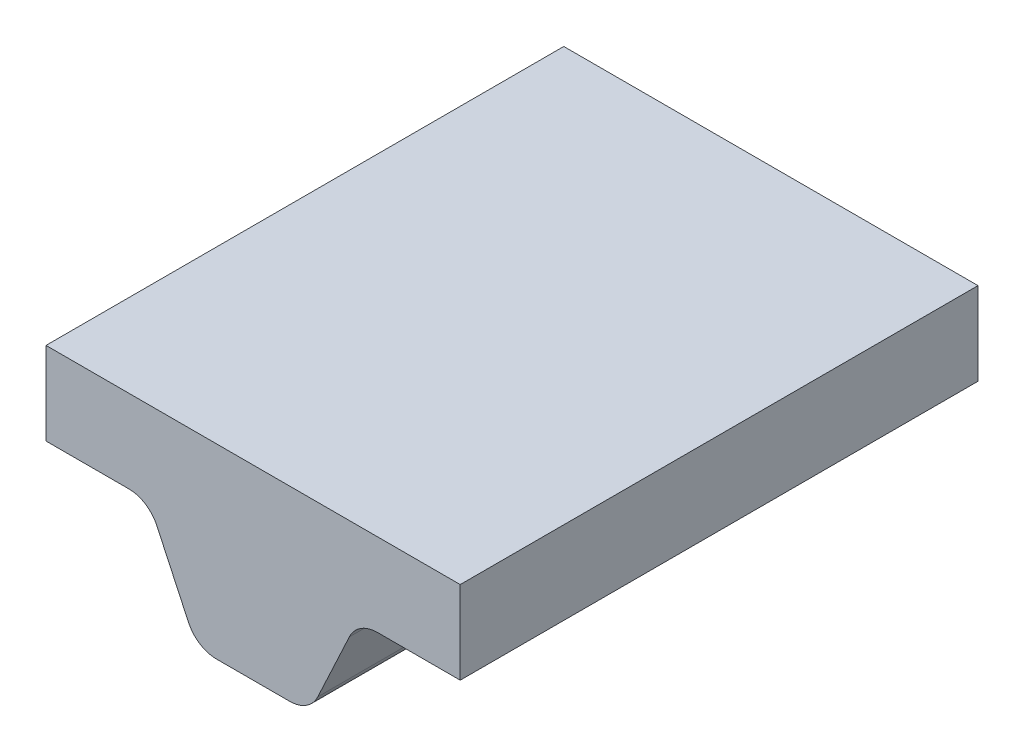
from build123d import *

# Parameters (mm, degrees)
BOSS_EXTRUDE1_DEPTH = 3.175


with BuildPart() as part:
    # Sketch1 → Boss-Extrude1 (new, symmetric)
    with BuildSketch(Plane.XY):
        with BuildLine():
            Line((2.54, -0.508), (2.54, 0.508))
            Line((2.54, 0.508), (-2.54, 0.508))
            Line((-2.54, 0.508), (-2.54, -0.508))
            Line((-2.54, -0.508), (-1.524786699, -0.508))
            ThreePointArc((-1.524786699, -0.508), (-1.320612848, -0.567511251), (-1.18038974, -0.727405061))
            Line((-1.18038974, -0.727405061), (-0.792799534, -1.558594939))
            ThreePointArc((-0.792799534, -1.558594939), (-0.652576426, -1.718488749), (-0.448402575, -1.778))
            Line((-0.448402575, -1.778), (0.448402575, -1.778))
            ThreePointArc((0.448402575, -1.778), (0.652576426, -1.718488749), (0.792799534, -1.558594939))
            Line((0.792799534, -1.558594939), (1.18038974, -0.727405061))
            ThreePointArc((1.18038974, -0.727405061), (1.320612848, -0.567511251), (1.524786699, -0.508))
            Line((1.524786699, -0.508), (2.54, -0.508))
        make_face()
    extrude(amount=BOSS_EXTRUDE1_DEPTH, both=True)


solid = part.part
